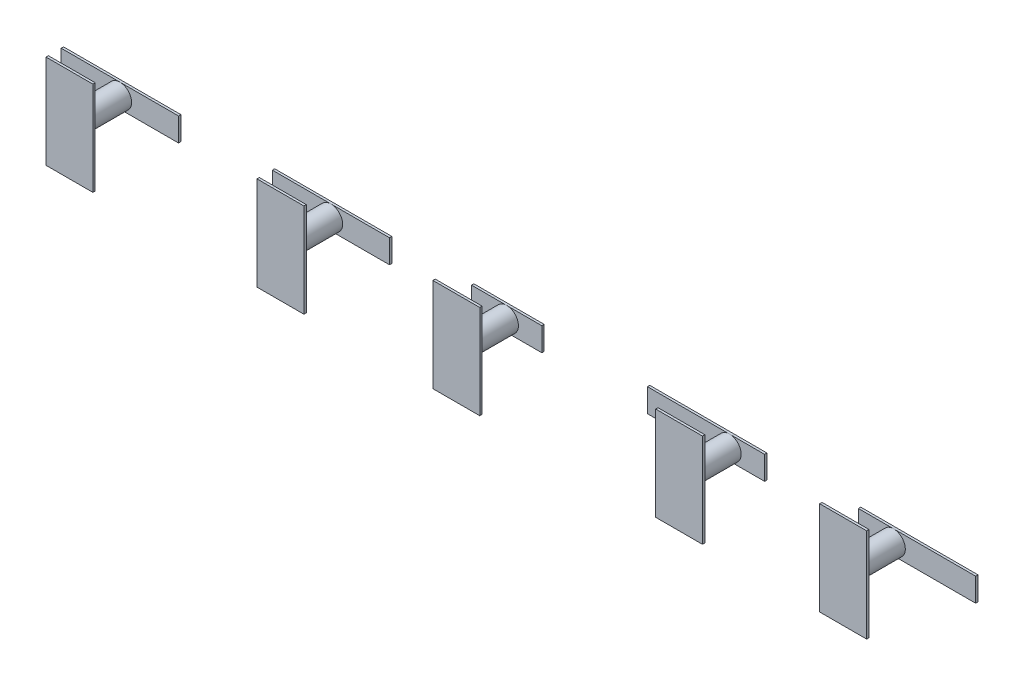
from build123d import *

# Parameters (mm, degrees)
BOSS_EXTRUDE1_DEPTH   = 0.2
SKETCH8_W             = 10
SKETCH8_H             = 2
BOSS_EXTRUDE1_2_DEPTH = 0.2
SKETCH8_W_2           = 6
BOSS_EXTRUDE1_3_DEPTH = 0.2
BOSS_EXTRUDE1_4_DEPTH = 0.2
BOSS_EXTRUDE1_5_DEPTH = 0.2
SKETCH10_R            = 1
BOSS_EXTRUDE2_DEPTH   = 4.5
BOSS_EXTRUDE2_2_DEPTH = 4.5
BOSS_EXTRUDE2_3_DEPTH = 4.5
BOSS_EXTRUDE2_4_DEPTH = 4.5
BOSS_EXTRUDE2_5_DEPTH = 4.5
SKETCH11_W            = 4
SKETCH11_H            = 8
BOSS_EXTRUDE3_DEPTH   = 0.2


with BuildPart() as part:
    # Sketch8 → Boss-Extrude1 (new body)
    with BuildSketch(Plane.XY.offset(0.5)):
        Polygon((-21, 1), (-17, 1), (-11, 1), (-11, -1), (-17, -1), (-21, -1), align=None)
    extrude(amount=BOSS_EXTRUDE1_DEPTH)


with BuildPart() as body_2:
    # Sketch8 → Boss-Extrude1 2 (new body)
    with BuildSketch(Plane.XY.offset(0.5)):
        with Locations((-34, 0)):
            Rectangle(SKETCH8_W, SKETCH8_H)
    extrude(amount=BOSS_EXTRUDE1_2_DEPTH)


with BuildPart() as body_3:
    # Sketch8 → Boss-Extrude1 3 (new body)
    with BuildSketch(Plane.XY.offset(0.5)):
        with Locations((-1, 0)):
            Rectangle(SKETCH8_W_2, SKETCH8_H)
    extrude(amount=BOSS_EXTRUDE1_3_DEPTH)


with BuildPart() as body_4:
    # Sketch8 → Boss-Extrude1 4 (new body)
    with BuildSketch(Plane.XY.offset(0.5)):
        with Locations((16, 0)):
            Rectangle(SKETCH8_W, SKETCH8_H)
    extrude(amount=BOSS_EXTRUDE1_4_DEPTH)


with BuildPart() as body_5:
    # Sketch8 → Boss-Extrude1 5 (new body)
    with BuildSketch(Plane.XY.offset(0.5)):
        with Locations((34, 0)):
            Rectangle(SKETCH8_W, SKETCH8_H)
    extrude(amount=BOSS_EXTRUDE1_5_DEPTH)


with BuildPart() as body_6:
    # Sketch10 → Boss-Extrude2 (new body)
    with BuildSketch(Plane.XY.offset(5)):
        with Locations((-34, 0)):
            Circle(SKETCH10_R)
    extrude(amount=-BOSS_EXTRUDE2_DEPTH)



with BuildPart() as body_7:
    # Sketch10 → Boss-Extrude2 2 (new body)
    with BuildSketch(Plane.XY.offset(5)):
        with Locations((-16, 0)):
            Circle(SKETCH10_R)
    extrude(amount=-BOSS_EXTRUDE2_2_DEPTH)


with BuildPart() as body_8:
    # Sketch10 → Boss-Extrude2 3 (new body)
    with BuildSketch(Plane.XY.offset(5)):
        with Locations((-1, 0)):
            Circle(SKETCH10_R)
    extrude(amount=-BOSS_EXTRUDE2_3_DEPTH)


with BuildPart() as body_9:
    # Sketch10 → Boss-Extrude2 4 (new body)
    with BuildSketch(Plane.XY.offset(5)):
        with Locations((18, 0)):
            Circle(SKETCH10_R)
    extrude(amount=-BOSS_EXTRUDE2_4_DEPTH)


with BuildPart() as body_10:
    # Sketch10 → Boss-Extrude2 5 (new body)
    with BuildSketch(Plane.XY.offset(5)):
        with Locations((32, 0)):
            Circle(SKETCH10_R)
    extrude(amount=-BOSS_EXTRUDE2_5_DEPTH)


with BuildPart() as body_6_1:
    add(body_6.part)

    add(body_7.part)  # Boss-Extrude3 merges body 7

    add(body_8.part)  # Boss-Extrude3 merges body 8

    add(body_9.part)  # Boss-Extrude3 merges body 9

    add(body_10.part)  # Boss-Extrude3 merges body 10
    # Sketch11 → Boss-Extrude3 (add)
    with BuildSketch(Plane.XY.offset(5)):
        with Locations((-34, 0)):
            Rectangle(SKETCH11_W, SKETCH11_H)
        with Locations((-16, 0)):
            Rectangle(SKETCH11_W, SKETCH11_H)
        with Locations((-1, 0)):
            Rectangle(SKETCH11_W, SKETCH11_H)
        with Locations((18, 0)):
            Rectangle(SKETCH11_W, SKETCH11_H)
        with Locations((32, 0)):
            Rectangle(SKETCH11_W, SKETCH11_H)
    extrude(amount=-BOSS_EXTRUDE3_DEPTH)


solid = Compound([part.part, body_2.part, body_3.part, body_4.part, body_5.part, body_6_1.part])
